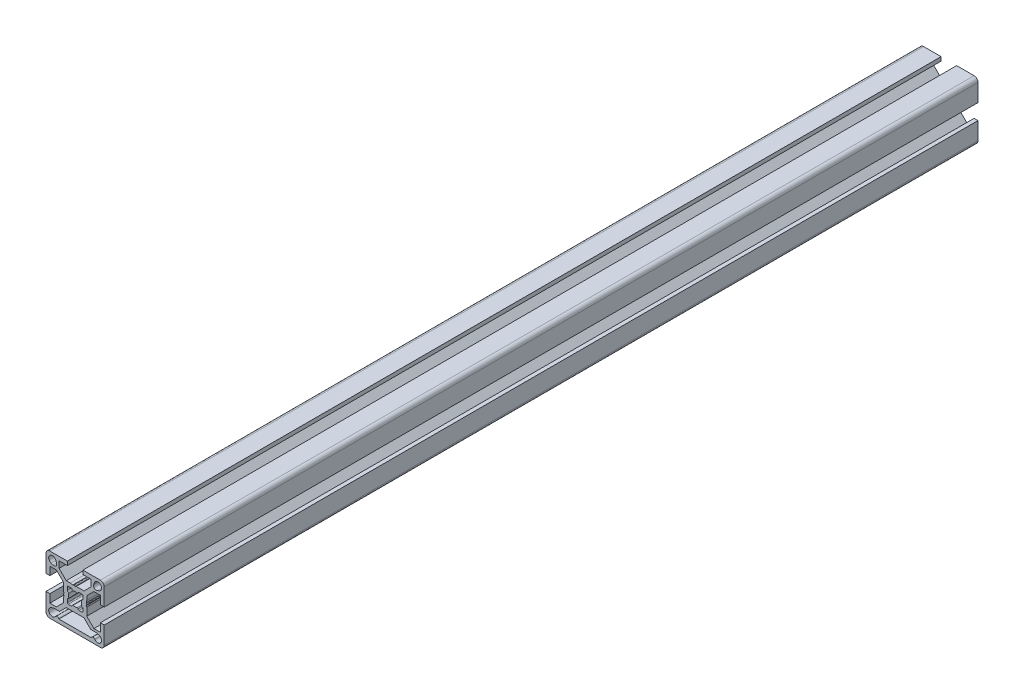
from build123d import *

# Parameters (mm, degrees)
ESTRUSIONE_ESTRUSIONE1_DEPTH = 450


with BuildPart() as part:
    # Schizzo1 → Estrusione-Estrusione1 (new body)
    with BuildSketch(Plane(origin=(0, 0, -450), x_dir=(-1, 0, 0), z_dir=(0, 0, -1))):
        with BuildLine():
            Line((-15, -4), (-15, -13))
            ThreePointArc((-15, -13), (-14.414213562, -14.414213562), (-13, -15))
            Line((-13, -15), (13, -15))
            ThreePointArc((13, -15), (14.414213562, -14.414213562), (15, -13))
            Line((15, -13), (15, -4))
            Line((15, -4), (13, -4))
            Line((13, -4), (13, -8.25))
            Line((13, -8.25), (9.664213562, -8.25))
            add(Edge.make_bspline(
                [(9.664213562, -8.25), (8.442809042, -7.028595479), (7.221404521, -5.807190958), (6, -4.585786438)],
                knots=[0, 0, 0, 0, 1, 1, 1, 1], degree=3))
            Line((6, -4.585786438), (6, -2.5))
            Line((6, -2.5), (5.750976629, -1.218885816))
            Line((5.750976629, -1.218885816), (5.933012788, -0.90358969))
            ThreePointArc((5.933012788, -0.90358969), (6, -0.653589753), (5.933012702, -0.403589838))
            Line((5.933012702, -0.403589838), (5.7, 0))
            Line((5.7, 0), (5.933012702, 0.403589838))
            ThreePointArc((5.933012702, 0.403589838), (5.982962913, 0.524180316), (6, 0.653589838))
            Line((6, 0.653589838), (6, 4.585786438))
            add(Edge.make_bspline(
                [(6, 4.585786438), (7.221404521, 5.807190958), (8.442809042, 7.028595479), (9.664213562, 8.25)],
                knots=[0, 0, 0, 0, 1, 1, 1, 1], degree=3))
            Line((9.664213562, 8.25), (13, 8.25))
            Line((13, 8.25), (13, 4))
            Line((13, 4), (15, 4))
            Line((15, 4), (15, 13))
            ThreePointArc((15, 13), (14.414213562, 14.414213562), (13, 15))
            Line((13, 15), (4, 15))
            Line((4, 15), (4, 13))
            Line((4, 13), (8.25, 13))
            Line((8.25, 13), (8.25, 9.664213562))
            add(Edge.make_bspline(
                [(8.25, 9.664213562), (7.028595479, 8.442809042), (5.807190958, 7.221404521), (4.585786438, 6)],
                knots=[0, 0, 0, 0, 1, 1, 1, 1], degree=3))
            Line((4.585786438, 6), (2.5, 6))
            Line((2.5, 6), (1.218885629, 5.750976592))
            Line((1.218885629, 5.750976592), (0.903589838, 5.933012702))
            ThreePointArc((0.903589838, 5.933012702), (0.653589838, 6), (0.403589838, 5.933012702))
            Line((0.403589838, 5.933012702), (0, 5.7))
            Line((0, 5.7), (-0.403589838, 5.933012702))
            ThreePointArc((-0.403589838, 5.933012702), (-0.524180316, 5.982962913), (-0.653589838, 6))
            Line((-0.653589838, 6), (-4.585786438, 6))
            add(Edge.make_bspline(
                [(-4.585786438, 6), (-5.807190958, 7.221404521), (-7.028595479, 8.442809042), (-8.25, 9.664213562)],
                knots=[0, 0, 0, 0, 1, 1, 1, 1], degree=3))
            Line((-8.25, 9.664213562), (-8.25, 13))
            Line((-8.25, 13), (-4, 13))
            Line((-4, 13), (-4, 15))
            Line((-4, 15), (-13, 15))
            ThreePointArc((-13, 15), (-14.414213562, 14.414213562), (-15, 13))
            Line((-15, 13), (-15, 4))
            Line((-15, 4), (-13, 4))
            Line((-13, 4), (-13, 8.25))
            Line((-13, 8.25), (-9.664213562, 8.25))
            add(Edge.make_bspline(
                [(-9.664213562, 8.25), (-8.442809042, 7.028595479), (-7.221404521, 5.807190958), (-6, 4.585786438)],
                knots=[0, 0, 0, 0, 1, 1, 1, 1], degree=3))
            Line((-6, 4.585786438), (-6, 2.5))
            Line((-6, 2.5), (-5.750976592, 1.218885629))
            Line((-5.750976592, 1.218885629), (-5.933012702, 0.903589838))
            ThreePointArc((-5.933012702, 0.903589838), (-6, 0.653589838), (-5.933012702, 0.403589838))
            Line((-5.933012702, 0.403589838), (-5.7, 0))
            Line((-5.7, 0), (-5.933012702, -0.403589838))
            ThreePointArc((-5.933012702, -0.403589838), (-5.982962913, -0.524180316), (-6, -0.653589838))
            Line((-6, -0.653589838), (-6, -4.585786438))
            add(Edge.make_bspline(
                [(-6, -4.585786438), (-7.221404521, -5.807190958), (-8.442809042, -7.028595479), (-9.664213562, -8.25)],
                knots=[0, 0, 0, 0, 1, 1, 1, 1], degree=3))
            Line((-9.664213562, -8.25), (-13, -8.25))
            Line((-13, -8.25), (-13, -4))
            Line((-13, -4), (-15, -4))
        make_face()
        with BuildLine():
            Line((12.349838066, 9.914583088), (11.34224826, 9.54785039))
            ThreePointArc((11.34224826, 9.54785039), (9.873470565, 9.873470565), (9.54785039, 11.34224826))
            Line((9.54785039, 11.34224826), (9.914583088, 12.349838066))
            ThreePointArc((9.914583088, 12.349838066), (13.043502884, 13.043502884), (12.349838066, 9.914583088))
        make_face(mode=Mode.SUBTRACT)
        with BuildLine():
            Line((-4.58, -6), (4.58, -6))
            add(Edge.make_bspline(
                [(4.58, -6), (5.73, -7.15), (6.88, -8.3), (8.03, -9.45)],
                knots=[0, 0, 0, 0, 1, 1, 1, 1], degree=3))
            Line((8.03, -9.45), (11.1, -9.45))
            Line((11.1, -9.45), (12.361944654, -9.919036981))
            ThreePointArc((12.361944654, -9.919036981), (13.194761433, -12.872897378), (10.127586207, -12.766543418))
            ThreePointArc((10.127586207, -12.766543418), (9.169403304, -12.336446483), (8.355281336, -13))
            Line((8.355281336, -13), (-8.355281336, -13))
            ThreePointArc((-8.355281336, -13), (-9.169403304, -12.336446483), (-10.127586207, -12.766543418))
            ThreePointArc((-10.127586207, -12.766543418), (-13.194761433, -12.872897378), (-12.361944654, -9.919036981))
            Line((-12.361944654, -9.919036981), (-11.1, -9.45))
            Line((-11.1, -9.45), (-8.03, -9.45))
            add(Edge.make_bspline(
                [(-8.03, -9.45), (-6.88, -8.3), (-5.73, -7.15), (-4.58, -6)],
                knots=[0, 0, 0, 0, 1, 1, 1, 1], degree=3))
        make_face(mode=Mode.SUBTRACT)
        with BuildLine():
            Line((-11.34224826, 9.54785039), (-12.349838066, 9.914583088))
            ThreePointArc((-12.349838066, 9.914583088), (-13.043502884, 13.043502884), (-9.914583088, 12.349838066))
            Line((-9.914583088, 12.349838066), (-9.54785039, 11.34224826))
            ThreePointArc((-9.54785039, 11.34224826), (-9.873470565, 9.873470565), (-11.34224826, 9.54785039))
        make_face(mode=Mode.SUBTRACT)
        with BuildLine():
            Line((4, 3.5), (4, 2))
            ThreePointArc((4, 2), (3.879005736, 1.673879391), (3.574581393, 1.505593673))
            ThreePointArc((3.574581393, 1.505593673), (3.295837094, 1.323326833), (3.251694243, 0.993219284))
            ThreePointArc((3.251694243, 0.993219284), (3.4, 0), (3.251694243, -0.993219284))
            ThreePointArc((3.251694243, -0.993219284), (3.295837094, -1.323326833), (3.574581393, -1.505593673))
            ThreePointArc((3.574581393, -1.505593673), (3.879005736, -1.673879391), (4, -2))
            Line((4, -2), (4, -3.5))
            ThreePointArc((4, -3.5), (3.853553391, -3.853553391), (3.5, -4))
            Line((3.5, -4), (2, -4))
            ThreePointArc((2, -4), (1.673879391, -3.879005736), (1.505593673, -3.574581393))
            ThreePointArc((1.505593673, -3.574581393), (1.323326833, -3.295837094), (0.993219284, -3.251694243))
            ThreePointArc((0.993219284, -3.251694243), (0, -3.4), (-0.993219284, -3.251694243))
            ThreePointArc((-0.993219284, -3.251694243), (-1.323326833, -3.295837094), (-1.505593673, -3.574581393))
            ThreePointArc((-1.505593673, -3.574581393), (-1.673879391, -3.879005736), (-2, -4))
            Line((-2, -4), (-3.5, -4))
            ThreePointArc((-3.5, -4), (-3.853553391, -3.853553391), (-4, -3.5))
            Line((-4, -3.5), (-4, -2))
            ThreePointArc((-4, -2), (-3.879005736, -1.673879391), (-3.574581393, -1.505593673))
            ThreePointArc((-3.574581393, -1.505593673), (-3.295837094, -1.323326833), (-3.251694243, -0.993219284))
            ThreePointArc((-3.251694243, -0.993219284), (-3.4, 0), (-3.251694243, 0.993219284))
            ThreePointArc((-3.251694243, 0.993219284), (-3.295837094, 1.323326833), (-3.574581393, 1.505593673))
            ThreePointArc((-3.574581393, 1.505593673), (-3.879005736, 1.673879391), (-4, 2))
            Line((-4, 2), (-4, 3.5))
            ThreePointArc((-4, 3.5), (-3.853553391, 3.853553391), (-3.5, 4))
            Line((-3.5, 4), (-2, 4))
            ThreePointArc((-2, 4), (-1.673879391, 3.879005736), (-1.505593673, 3.574581393))
            ThreePointArc((-1.505593673, 3.574581393), (-1.323326833, 3.295837094), (-0.993219284, 3.251694243))
            ThreePointArc((-0.993219284, 3.251694243), (0, 3.4), (0.993219284, 3.251694243))
            ThreePointArc((0.993219284, 3.251694243), (1.323326833, 3.295837094), (1.505593673, 3.574581393))
            ThreePointArc((1.505593673, 3.574581393), (1.673879391, 3.879005736), (2, 4))
            Line((2, 4), (3.5, 4))
            ThreePointArc((3.5, 4), (3.853553391, 3.853553391), (4, 3.5))
        make_face(mode=Mode.SUBTRACT)
    extrude(amount=-ESTRUSIONE_ESTRUSIONE1_DEPTH)


solid = part.part
